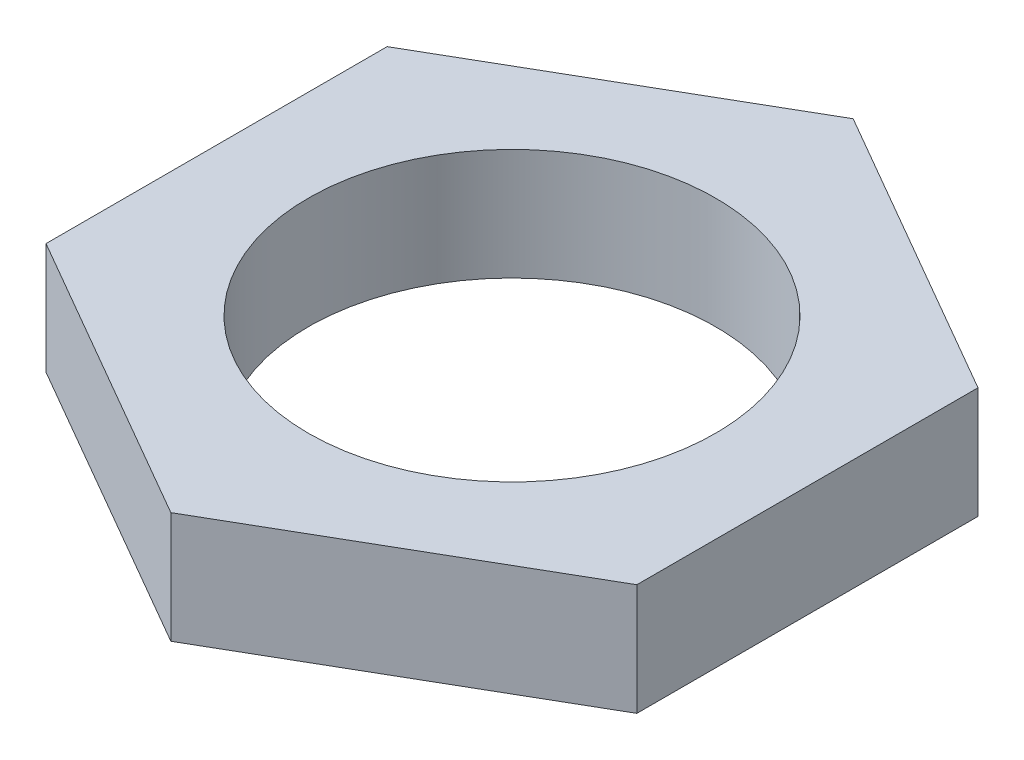
from build123d import *

# Parameters (mm, degrees)
BOSS_EXTRUDE1_DEPTH = 1.32
SKETCH2_R           = 2.413
CUT_EXTRUDE1_DEPTH  = 2.32


with BuildPart() as part:
    # Sketch1 → Boss-Extrude1 (new body)
    with BuildSketch(Plane(origin=(0, 0, 0), x_dir=(1, 0, 0), z_dir=(0, 1, 0))):
        Polygon((-3.5, 2.020725942), (-3.5, -2.020725942), (0, -4.041451884), (3.5, -2.020725942), (3.5, 2.020725942), (0, 4.041451884), align=None)
    extrude(amount=BOSS_EXTRUDE1_DEPTH)

    # Sketch2 → Cut-Extrude1 (cut, through all)
    with BuildSketch(Plane(origin=(0, 1.32, 0), x_dir=(1, 0, 0), z_dir=(0, 1, 0))):
        Circle(SKETCH2_R)
    extrude(amount=-CUT_EXTRUDE1_DEPTH, mode=Mode.SUBTRACT)


solid = part.part
